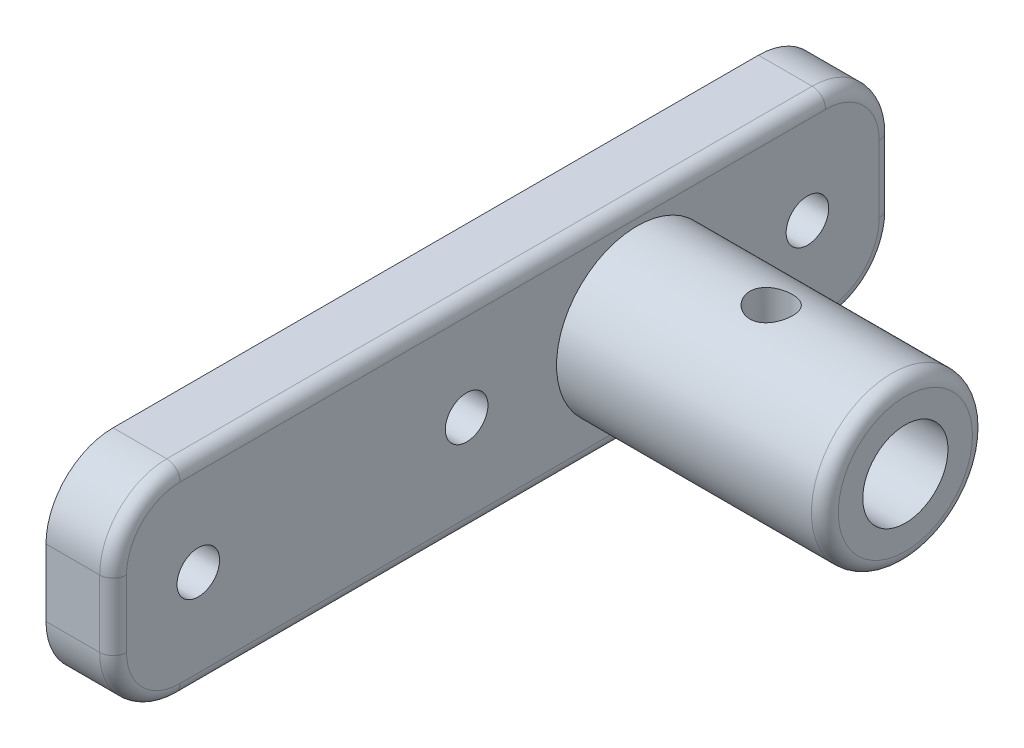
from build123d import *

# Parameters (mm, degrees)
SKETCH1_R           = 1.5875
BOSS_EXTRUDE1_DEPTH = 5
SKETCH2_R           = 6
SKETCH2_R_2         = 3.175
BOSS_EXTRUDE2_DEPTH = 20
FILLET1_R           = 5
FILLET2_R           = 1
SKETCH3_R           = 1.5875
CUT_EXTRUDE1_DEPTH  = 16
FILLET3_R           = 1
SKETCH4_R           = 3.175
CUT_EXTRUDE2_DEPTH  = 6


with BuildPart() as part:
    # Sketch1 → Boss-Extrude1 (new body)
    with BuildSketch(Plane(origin=(0, 0, 0), x_dir=(0, 0, -1), z_dir=(1, 0, 0))):
        Polygon((-24.516144589, 8.853546087), (13.583855411, 8.853546087), (13.583855411, 23.853546087), (-24.516144589, 23.853546087), (-44.516144589, 23.853546087), (-44.516144589, 8.853546087), align=None)
        with Locations((-18.166144589, 16.353546087)):
            Circle(SKETCH1_R, mode=Mode.SUBTRACT)
        with Locations((7.233855411, 16.353546087)):
            Circle(SKETCH1_R, mode=Mode.SUBTRACT)
        with Locations((-38.166144589, 16.353546087)):
            Circle(SKETCH1_R, mode=Mode.SUBTRACT)
    extrude(amount=BOSS_EXTRUDE1_DEPTH)

    # Sketch2 → Boss-Extrude2 (add)
    with BuildSketch(Plane(origin=(5, 0, 0), x_dir=(0, 0, -1), z_dir=(1, 0, 0))):
        with Locations((-5.466144589, 16.353546087)):
            Circle(SKETCH2_R)
        with Locations((-5.466144589, 16.353546087)):
            Circle(SKETCH2_R_2, mode=Mode.SUBTRACT)
    extrude(amount=BOSS_EXTRUDE2_DEPTH)

    # Fillet1
    fillet1_edges = [part.edges().sort_by_distance(p)[0] for p in [
        (2.5, 8.853546087, 44.516144589),
        (2.5, 23.853546087, 44.516144589),
        (2.5, 23.853546087, -13.583855411),
        (2.5, 8.853546087, -13.583855411),
    ]]
    fillet(fillet1_edges, radius=FILLET1_R)

    # Fillet2
    fillet2_edges = [part.edges().sort_by_distance(p)[0] for p in [
        (25, 16.353546087, 11.466144589),
    ]]
    fillet(fillet2_edges, radius=FILLET2_R)

    # Sketch3 → Cut-Extrude1 (cut, through all)
    with BuildSketch(Plane(origin=(0, 23.853546087, 0), x_dir=(1, 0, 0), z_dir=(0, 1, 0))):
        with Locations((15, -5.466144589)):
            Circle(SKETCH3_R)
    extrude(amount=-CUT_EXTRUDE1_DEPTH, mode=Mode.SUBTRACT)

    # Fillet3
    fillet3_edges = [part.edges().sort_by_distance(p)[0] for p in [
        (5, 8.853546087, 15.466144589),
        (5, 16.353546087, 44.516144589),
        (5, 16.353546087, -13.583855411),
        (5, 23.853546087, 15.466144589),
        (5, 22.389079993, -12.119389316),
        (5, 10.318012181, -12.119389316),
        (5, 22.389079993, 43.051678495),
        (5, 10.318012181, 43.051678495),
    ]]
    fillet(fillet3_edges, radius=FILLET3_R)

    # Sketch4 → Cut-Extrude2 (cut, through all)
    with BuildSketch(Plane(origin=(5, 0, 0), x_dir=(0, 0, -1), z_dir=(1, 0, 0))):
        with Locations((-5.466144589, 16.353546087)):
            Circle(SKETCH4_R)
    extrude(amount=-CUT_EXTRUDE2_DEPTH, mode=Mode.SUBTRACT)


solid = part.part
